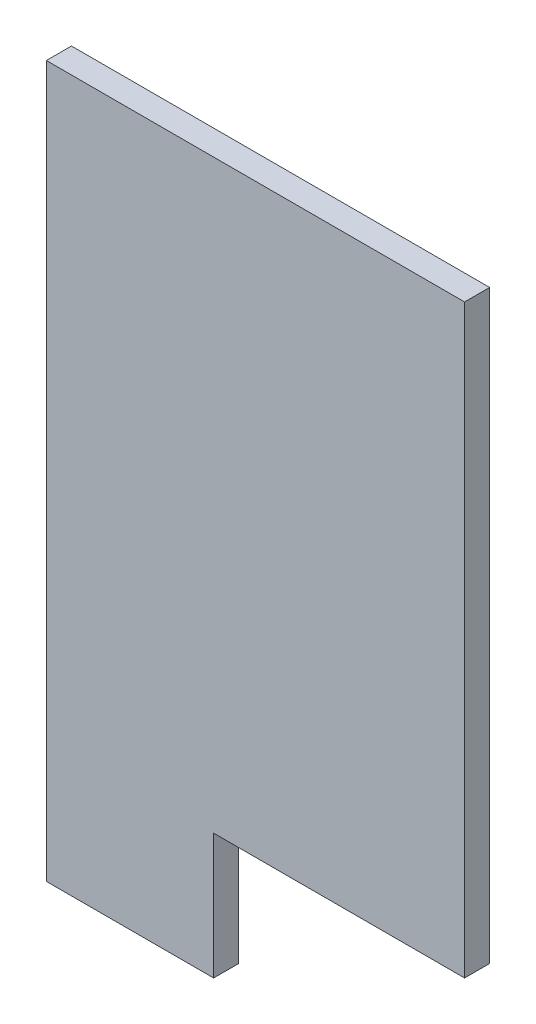
from build123d import *

# Parameters (mm, degrees)
EXTRUDE_1_DEPTH = 3


with BuildPart() as part:
    # 草图1 → 凸台-拉伸1 (new body)
    with BuildSketch(Plane.XY):
        Polygon((-25, 35), (25, 35), (25, -35), (-5, -35), (-5, -50), (-25, -50), (-25, -35), align=None)
    extrude(amount=EXTRUDE_1_DEPTH)


solid = part.part
